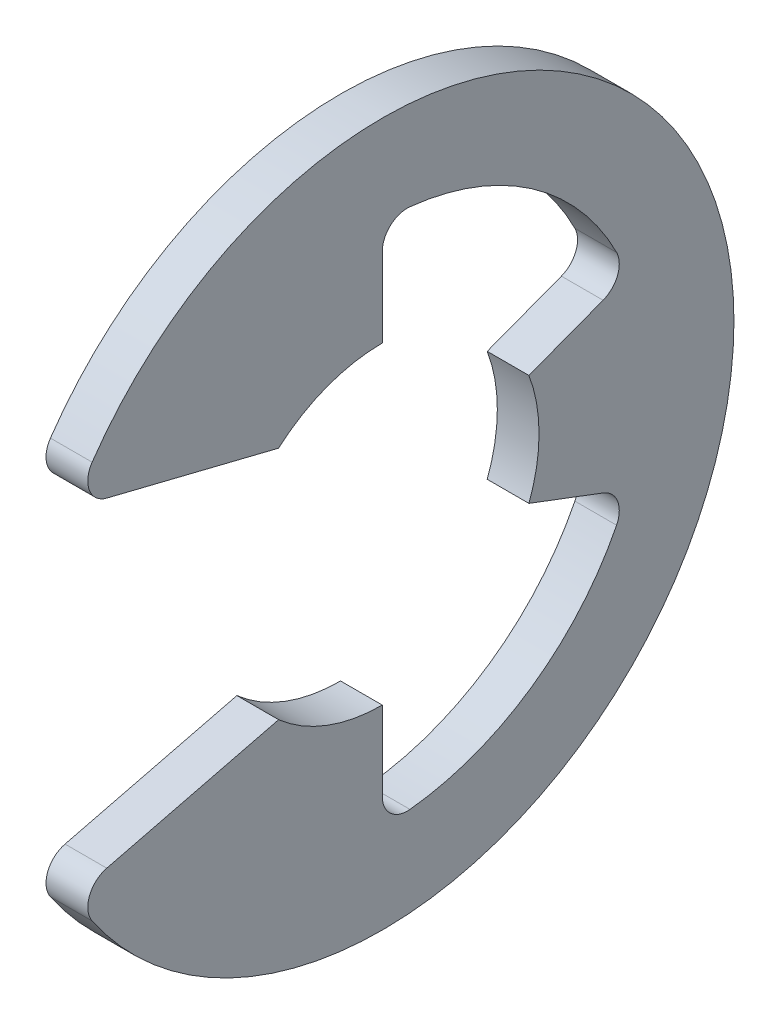
from build123d import *

# Parameters (mm, degrees)
EXTRUDE1_DEPTH = 0.35
FILLET1_R      = 0.42


with BuildPart() as part:
    # Sketch1 → Extrude1 (new body, symmetric)
    with BuildSketch(Plane(origin=(0, 0, 0), x_dir=(0, 0, -1), z_dir=(1, 0, 0))):
        with BuildLine():
            Line((-5.178952745, -2.826384345), (-1.739581487, -1.9725))
            ThreePointArc((-1.739581487, -1.9725), (-0.929845417, -2.460139732), (0, -2.63))
            Line((0, -2.63), (0, -4.402580645))
            ThreePointArc((0, -4.402580645), (2.502987341, -3.621846312), (4.118237098, -1.556547314))
            Line((4.118237098, -1.556547314), (2.460139732, -0.929845417))
            ThreePointArc((2.460139732, -0.929845417), (2.63, 0), (2.460139732, 0.929845417))
            Line((2.460139732, 0.929845417), (4.118237098, 1.556547314))
            ThreePointArc((4.118237098, 1.556547314), (2.502987341, 3.621846312), (0, 4.402580645))
            Line((0, 4.402580645), (0, 2.63))
            ThreePointArc((0, 2.63), (-0.929845417, 2.460139732), (-1.739581487, 1.9725))
            Line((-1.739581487, 1.9725), (-5.178952745, 2.826384345))
            ThreePointArc((-5.178952745, 2.826384345), (5.9, 0), (-5.178952745, -2.826384345))
        make_face()
    extrude(amount=EXTRUDE1_DEPTH, both=True)

    # Fillet1
    fillet1_edges = [part.edges().sort_by_distance(p)[0] for p in [
        (0, -2.826384345, 5.178952745),
        (0, -4.402580645, 0),
        (0, -1.556547314, -4.118237098),
        (0, 1.556547314, -4.118237098),
        (0, 4.402580645, 0),
        (0, 2.826384345, 5.178952745),
    ]]
    fillet(fillet1_edges, radius=FILLET1_R)


solid = part.part
